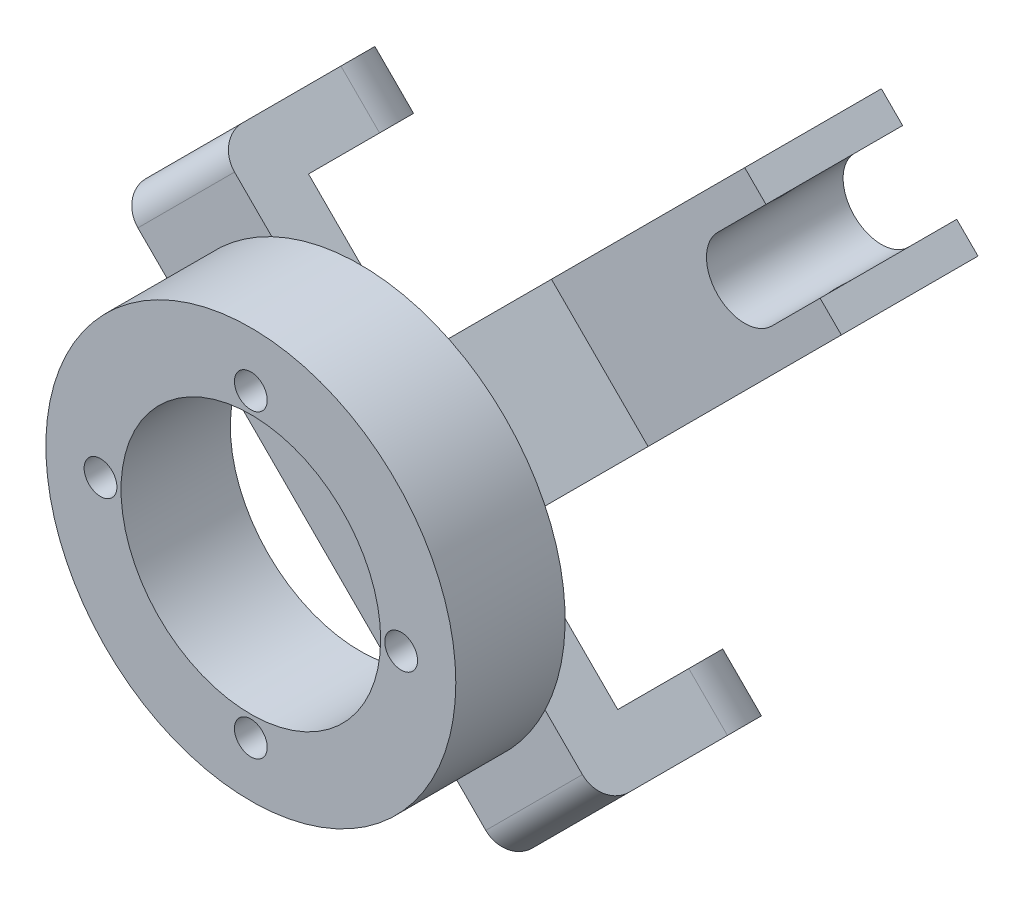
from build123d import *

# Parameters (mm, degrees)
SZKIC1_R                    = 75
DODANIE_WYCI_GNI_CIE1_DEPTH = 40
SZKIC2_R                    = 6
WYTNIJ_WYCI_GNI_CIE1_DEPTH  = 40
SZKIC3_R                    = 47.5
WYTNIJ_WYCI_GNI_CIE2_DEPTH  = 40
SZKIC4_W                    = 50
SZKIC4_H                    = 20
DODANIE_WYCI_GNI_CIE2_DEPTH = 100
SZKIC6_W                    = 50
SZKIC6_H                    = 49.999779654
DODANIE_WYCI_GNI_CIE3_DEPTH = 20
SZKIC7_R                    = 7
WYTNIJ_WYCI_GNI_CIE3_DEPTH  = 226
ZAOKR_GLENIE1_R             = 24
ZAOKR_GLENIE2_R             = 10
DODANIE_WYCI_GNI_CIE4_DEPTH = 100
SZKIC10_W                   = 50
SZKIC10_H                   = 50
DODANIE_WYCI_GNI_CIE5_DEPTH = 100
SZKIC12_R                   = 7
WYTNIJ_WYCI_GNI_CIE5_DEPTH  = 163.5
WYTNIJ_WYCI_GNI_CIE6_DEPTH  = 161


with BuildPart() as part:
    # Szkic1 → Dodanie-wyciągnięcie1 (new body)
    with BuildSketch(Plane.XY):
        Circle(SZKIC1_R)
    extrude(amount=DODANIE_WYCI_GNI_CIE1_DEPTH)

    # Szkic2 → Wytnij-wyciągnięcie1 (cut)
    with BuildSketch(Plane.XY.offset(40)):
        with Locations((-55, 0)):
            Circle(SZKIC2_R)
        with Locations((0, 55)):
            Circle(SZKIC2_R)
        with Locations((55, 0)):
            Circle(SZKIC2_R)
        with Locations((0, -55)):
            Circle(SZKIC2_R)
    extrude(amount=-WYTNIJ_WYCI_GNI_CIE1_DEPTH, mode=Mode.SUBTRACT)

    # Szkic3 → Wytnij-wyciągnięcie2 (cut)
    with BuildSketch(Plane.XY.offset(40)):
        Circle(SZKIC3_R)
    extrude(amount=-WYTNIJ_WYCI_GNI_CIE2_DEPTH, mode=Mode.SUBTRACT)

    # Szkic4 → Dodanie-wyciągnięcie2 (add, symmetric)
    with BuildSketch(Plane(origin=(0, 0, 0), x_dir=(-0.707106781, -0.707106781, 0), z_dir=(0.707106781, -0.707106781, 0))):
        with Locations((0, 10)):
            Rectangle(SZKIC4_W, SZKIC4_H)
    extrude(amount=DODANIE_WYCI_GNI_CIE2_DEPTH, both=True)

    # Szkic6 → Dodanie-wyciągnięcie3 (add)
    with BuildSketch(Plane(origin=(70.710678119, -70.710678119, 0), x_dir=(0, 0, -1), z_dir=(0.707106781, -0.707106781, 0))):
        with Locations((45, 0.000110173)):
            Rectangle(SZKIC6_W, SZKIC6_H)
    dodanie_wyci_gni_cie3 = extrude(amount=-DODANIE_WYCI_GNI_CIE3_DEPTH)

    # Lustro1: Dodanie-wyciągnięcie3 across plane
    add(dodanie_wyci_gni_cie3.mirror(Plane(origin=(0, 0, 0), x_dir=(0, 0, 1), z_dir=(0.707106781, -0.707106781, 0))))

    # Szkic7 → Wytnij-wyciągnięcie3 (cut, through all)
    with BuildSketch(Plane(origin=(-70.710678119, 70.710678119, 0), x_dir=(0, 0, 1), z_dir=(-0.707106781, 0.707106781, 0))):
        with Locations((-45, 0)):
            Circle(SZKIC7_R)
    extrude(amount=-WYTNIJ_WYCI_GNI_CIE3_DEPTH, mode=Mode.SUBTRACT)

    # Zaokrąglenie1
    zaokr_glenie1_edges = [part.edges().sort_by_distance(p)[0] for p in [
        (81.317279836, -45.961940777, -70),
        (45.962096585, -81.317124028, -70),
        (-81.317124028, 45.962096585, -70),
        (-45.961940777, 81.317279836, -70),
    ]]
    fillet(zaokr_glenie1_edges, radius=ZAOKR_GLENIE1_R)

    # Zaokrąglenie2
    zaokr_glenie2_edges = [part.edges().sort_by_distance(p)[0] for p in [
        (-70.710678119, 70.710678119, 0),
        (70.710678119, -70.710678119, 0),
    ]]
    fillet(zaokr_glenie2_edges, radius=ZAOKR_GLENIE2_R)

    # Szkic8 → Dodanie-wyciągnięcie4 (add)
    with BuildSketch(Plane(origin=(0, 0, -20), x_dir=(-1, 0, 0), z_dir=(0, 0, -1))):
        Polygon((0, 35.355339059), (35.355339059, 0), (0, -35.355339059), (-35.355339059, 0), align=None)
    extrude(amount=DODANIE_WYCI_GNI_CIE4_DEPTH)

    # Szkic10 → Dodanie-wyciągnięcie5 (add)
    with BuildSketch(Plane(origin=(17.67766953, 17.67766953, 0), x_dir=(0, 0, -1), z_dir=(0.707106781, 0.707106781, 0))):
        with Locations((95, 0)):
            Rectangle(SZKIC10_W, SZKIC10_H)
    extrude(amount=DODANIE_WYCI_GNI_CIE5_DEPTH)

    # Szkic12 → Wytnij-wyciągnięcie5 (cut, through all)
    with BuildSketch(Plane(origin=(17.67766953, -17.67766953, 0), x_dir=(0, 0, -1), z_dir=(0.707106781, -0.707106781, 0))):
        with Locations((95, 105)):
            Circle(SZKIC12_R)
    extrude(amount=-WYTNIJ_WYCI_GNI_CIE5_DEPTH, mode=Mode.SUBTRACT)

    # Szkic14 → Wytnij-wyciągnięcie6 (cut, through all)
    with BuildSketch(Plane(origin=(0, 0, -120), x_dir=(-1, 0, 0), z_dir=(0, 0, -1))):
        with BuildLine():
            Line((-80.610173055, 60.811183182), (-98.287842585, 78.488852712))
            Line((-98.287842585, 78.488852712), (-78.488852712, 98.287842585))
            Line((-78.488852712, 98.287842585), (-60.811183182, 80.610173055))
            ThreePointArc((-60.811183182, 80.610173055), (-60.811183182, 60.811183182), (-80.610173055, 60.811183182))
        make_face()
    extrude(amount=-WYTNIJ_WYCI_GNI_CIE6_DEPTH, mode=Mode.SUBTRACT)


solid = part.part
